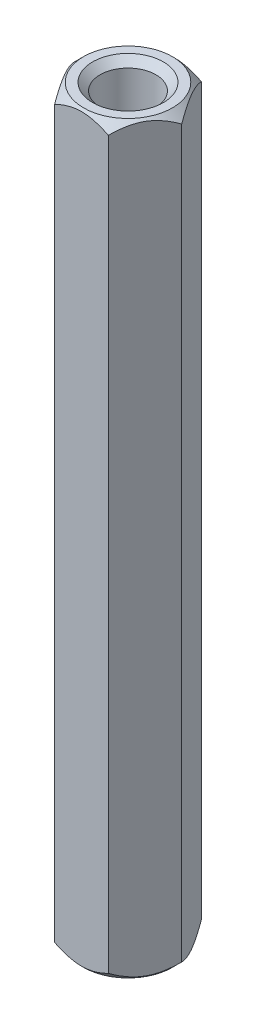
from build123d import *

# Parameters (mm, degrees)
SKETCH1_R           = 1.905
BOSS_EXTRUDE1_DEPTH = 50.8
CHAMFER1_SIZE       = 0.508


with BuildPart() as part:
    # Sketch1 → Boss-Extrude1 (new body)
    with BuildSketch(Plane(origin=(0, 0, 0), x_dir=(1, 0, 0), z_dir=(0, 1, 0))):
        Polygon((3.666174209, 0), (1.833087105, 3.175), (-1.833087105, 3.175), (-3.666174209, 0), (-1.833087105, -3.175), (1.833087105, -3.175), align=None)
        Circle(SKETCH1_R, mode=Mode.SUBTRACT)
    extrude(amount=BOSS_EXTRUDE1_DEPTH)

    # Sketch2 → Cut-Revolve1 (revolve, cut)
    with BuildSketch(Plane.XY):
        Polygon((3.666174209, 0), (3.031174209, 0), (3.950242751, 0.919068541), align=None)
        Polygon((3.950242751, 49.880931459), (3.666174209, 50.8), (3.031174209, 50.8), align=None)
    revolve(axis=Axis((0, 49.880931459, 0), (0, -1, 0)), mode=Mode.SUBTRACT)

    # Chamfer1
    chamfer1_edges = [part.edges().sort_by_distance(p)[0] for p in [
        (-1.905, 0, 0),
        (-1.905, 50.8, 0),
    ]]
    chamfer(chamfer1_edges, length=CHAMFER1_SIZE)


solid = part.part
